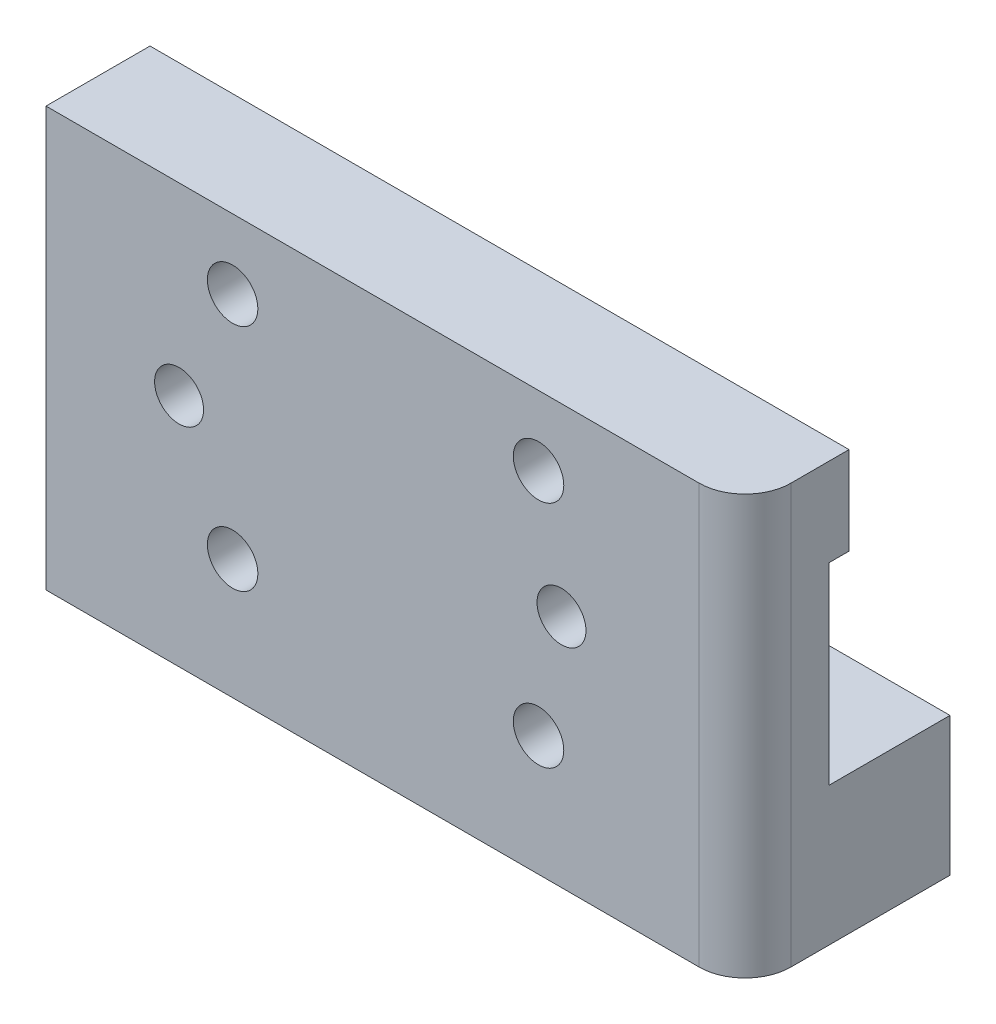
from build123d import *

# Parameters (mm, degrees)
SALIENTE_EXTRUIR1_START      = 0.1
SALIENTE_EXTRUIR1_DEPTH      = 1.3
SALIENTE_EXTRUIR2_START      = 0.1
SALIENTE_EXTRUIR2_DEPTH      = 1.3
SALIENTE_EXTRUIR2_DEPTH_BACK = 6.6
CROQUIS2_W                   = 45.7
CROQUIS2_H                   = 27.4
CROQUIS2_R                   = 1.65
CROQUIS2_R_2                 = 1.6
SALIENTE_EXTRUIR3_DEPTH      = 5.5
REDONDEO1_R                  = 3


with BuildPart() as part:
    # Croquis1 → Saliente-Extruir1 (new body)
    with BuildSketch(Plane.XY.offset(SALIENTE_EXTRUIR1_START)):
        with BuildLine():
            Line((-105.35, -3.3), (-105.35, -9.05))
            Line((-105.35, -9.05), (-94.282475165, -9.05))
            ThreePointArc((-94.282475165, -9.05), (-93.803420224, -6.334895379), (-91.5, -7.85))
            ThreePointArc((-91.5, -7.85), (-91.634895379, -8.503420224), (-92.017524835, -9.05))
            Line((-92.017524835, -9.05), (-74.282475165, -9.05))
            ThreePointArc((-74.282475165, -9.05), (-73.803420224, -6.334895379), (-71.5, -7.85))
            ThreePointArc((-71.5, -7.85), (-71.634895379, -8.503420224), (-72.017524835, -9.05))
            Line((-72.017524835, -9.05), (-59.65, -9.05))
            Line((-59.65, -9.05), (-59.65, -3.3))
            Line((-59.65, -3.3), (-105.35, -3.3))
        make_face()
    extrude(amount=SALIENTE_EXTRUIR1_DEPTH)



with BuildPart() as body_2:
    # Croquis1_3 → Saliente-Extruir2 (new, two sides)
    with BuildSketch(Plane.XY.offset(SALIENTE_EXTRUIR2_START)) as saliente_extruir2_sk:
        with BuildLine():
            Line((-105.35, -21.65), (-105.35, -30.7))
            Line((-105.35, -30.7), (-59.65, -30.7))
            Line((-59.65, -30.7), (-59.65, -21.65))
            Line((-59.65, -21.65), (-72.017510495, -21.65))
            ThreePointArc((-72.017510495, -21.65), (-71.634891475, -22.196575296), (-71.5, -22.849986467))
            ThreePointArc((-71.5, -22.849986467), (-73.803411171, -24.365094992), (-74.282489505, -21.65))
            Line((-74.282489505, -21.65), (-92.017510495, -21.65))
            ThreePointArc((-92.017510495, -21.65), (-91.634891475, -22.196575296), (-91.5, -22.849986467))
            ThreePointArc((-91.5, -22.849986467), (-93.803411171, -24.365094992), (-94.282489505, -21.65))
            Line((-94.282489505, -21.65), (-105.35, -21.65))
        make_face()
    extrude(amount=SALIENTE_EXTRUIR2_DEPTH)
    extrude(saliente_extruir2_sk.sketch, amount=-SALIENTE_EXTRUIR2_DEPTH_BACK)


with BuildPart() as part_1:
    add(part.part)

    add(body_2.part)  # Saliente-Extruir3 merges body 2
    # Croquis2 → Saliente-Extruir3 (add)
    with BuildSketch(Plane.XY.offset(1.4)):
        with Locations((-82.5, -17)):
            Rectangle(CROQUIS2_W, CROQUIS2_H)
        with Locations(Location((-93.15, -7.85, 0), (0, 0, 226.658241773))):
            Circle(CROQUIS2_R, mode=Mode.SUBTRACT)
        with Locations(Location((-73.15, -7.85, 0), (0, 0, 226.658241773))):
            Circle(CROQUIS2_R, mode=Mode.SUBTRACT)
        with Locations(Location((-93.15, -22.849986467, 0), (0, 0, 133.342442907))):
            Circle(CROQUIS2_R, mode=Mode.SUBTRACT)
        with Locations(Location((-73.15, -22.849986467, 0), (0, 0, 133.342442907))):
            Circle(CROQUIS2_R, mode=Mode.SUBTRACT)
        with Locations((-96.65, -15.35)):
            Circle(CROQUIS2_R_2, mode=Mode.SUBTRACT)
        with Locations((-71.65, -15.35)):
            Circle(CROQUIS2_R_2, mode=Mode.SUBTRACT)
    extrude(amount=SALIENTE_EXTRUIR3_DEPTH)

    # Redondeo1
    redondeo1_edges = [part_1.edges().sort_by_distance(p)[0] for p in [
        (-59.65, -17, 6.9),
    ]]
    fillet(redondeo1_edges, radius=REDONDEO1_R)


solid = part_1.part
